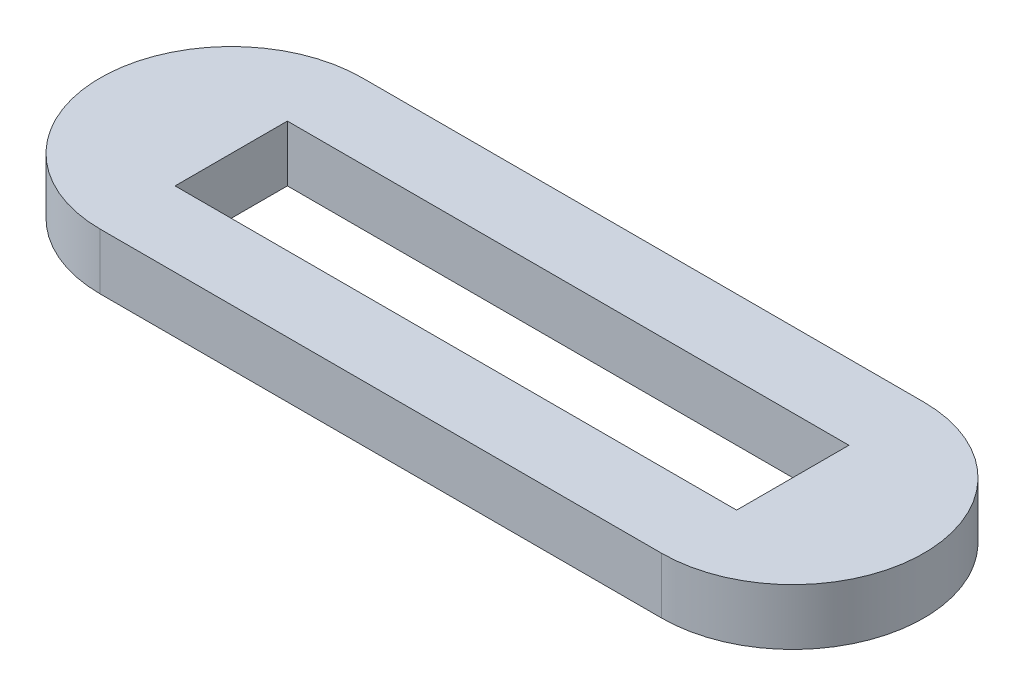
from build123d import *

# Parameters (mm, degrees)
SKETCH1_W           = 150
SKETCH1_H           = 30
BOSS_EXTRUDE1_DEPTH = 15


with BuildPart() as part:
    # Sketch1 → Boss-Extrude1 (new body)
    with BuildSketch(Plane(origin=(0, 0, 0), x_dir=(1, 0, 0), z_dir=(0, 1, 0))):
        with BuildLine():
            Line((-75, 35), (75, 35))
            ThreePointArc((75, 35), (110, 0), (75, -35))
            Line((75, -35), (-75, -35))
            ThreePointArc((-75, -35), (-110, 0), (-75, 35))
        make_face()
        Rectangle(SKETCH1_W, SKETCH1_H, mode=Mode.SUBTRACT)
    extrude(amount=BOSS_EXTRUDE1_DEPTH)


solid = part.part
